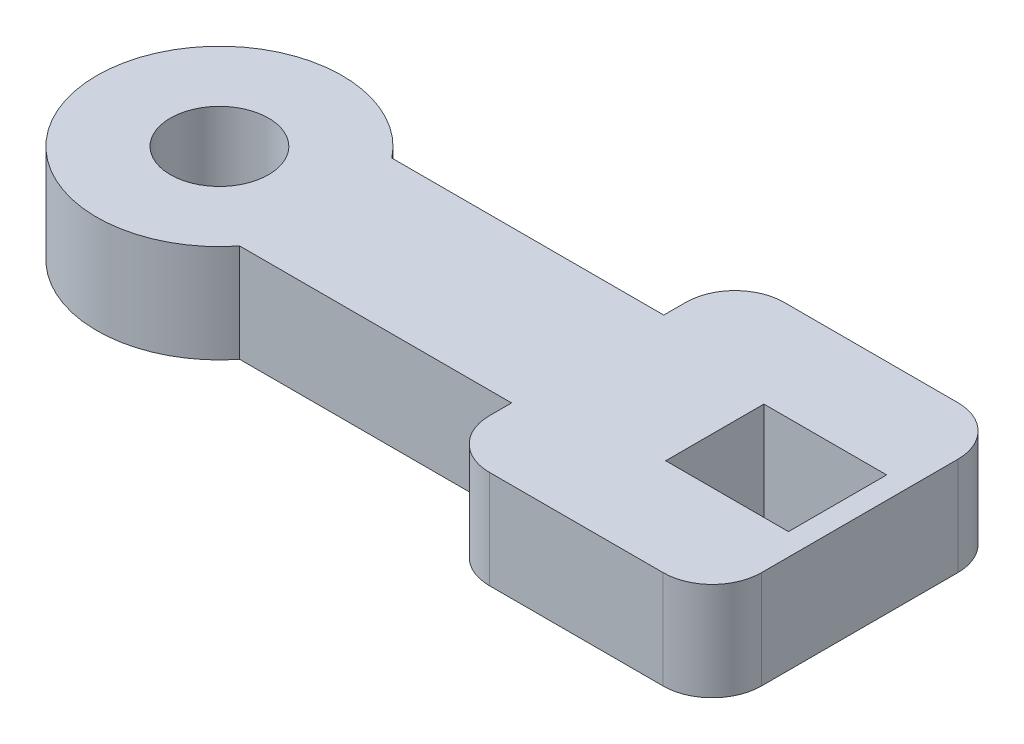
from build123d import *

# Parameters (mm, degrees)
SKETCH1_R           = 1
SKETCH1_W           = 2.5
SKETCH1_H           = 2
BOSS_EXTRUDE4_DEPTH = 2


with BuildPart() as part:
    # Sketch1 → Boss-Extrude4 (new body)
    with BuildSketch(Plane(origin=(0, 0, 0), x_dir=(1, 0, 0), z_dir=(0, 1, 0))):
        with BuildLine():
            Line((4.461504525, -1.55), (10, -1.55))
            Line((10, -1.55), (10, -2))
            ThreePointArc((10, -2), (10.292893219, -2.707106781), (11, -3))
            Line((11, -3), (14.538495475, -3))
            ThreePointArc((14.538495475, -3), (15.245602257, -2.707106781), (15.538495475, -2))
            Line((15.538495475, -2), (15.538495475, 2))
            ThreePointArc((15.538495475, 2), (15.245602257, 2.707106781), (14.538495475, 3))
            Line((14.538495475, 3), (11, 3))
            ThreePointArc((11, 3), (10.292893219, 2.707106781), (10, 2))
            Line((10, 2), (10, 1.55))
            Line((10, 1.55), (4.461504525, 1.55))
            ThreePointArc((4.461504525, 1.55), (0, 0), (4.461504525, -1.55))
        make_face()
        with Locations((2.5, 0)):
            Circle(SKETCH1_R, mode=Mode.SUBTRACT)
        with Locations((13.839657546, 0)):
            Rectangle(SKETCH1_W, SKETCH1_H, mode=Mode.SUBTRACT)
    extrude(amount=BOSS_EXTRUDE4_DEPTH)


solid = part.part
